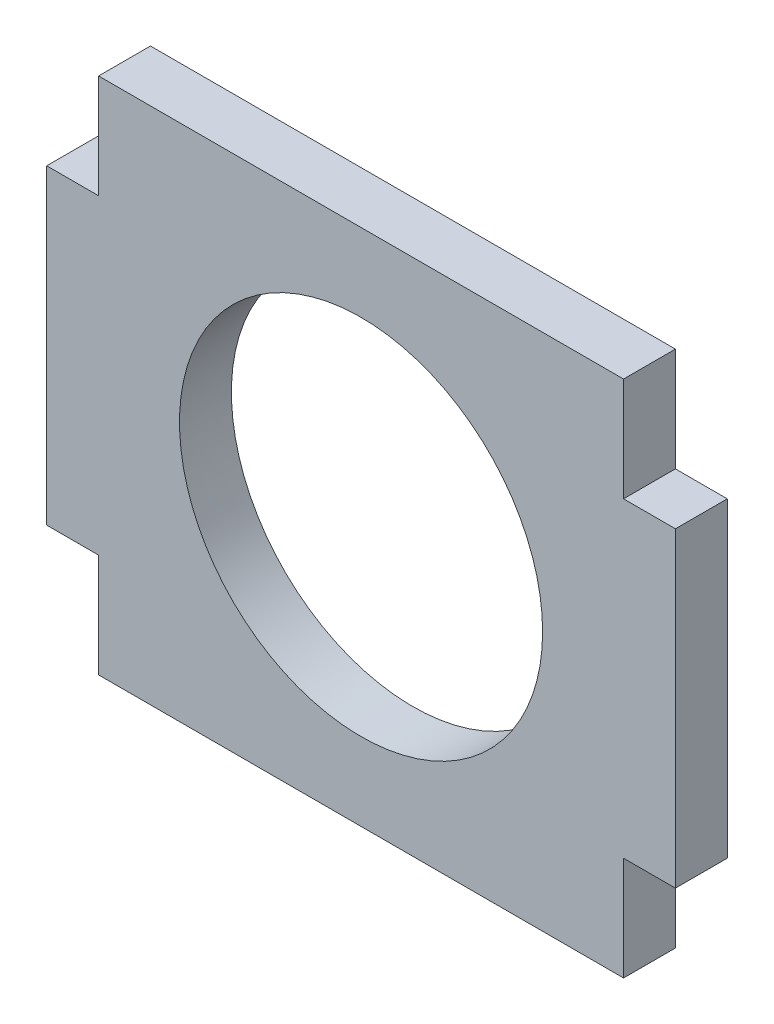
from build123d import *

# Parameters (mm, degrees)
SKETCH1_R           = 11.1125
BOSS_EXTRUDE1_DEPTH = 3.175


with BuildPart() as part:
    # Sketch1 → Boss-Extrude1 (new body)
    with BuildSketch(Plane.XY):
        Polygon((-19.2405, -9.525), (-19.2405, 9.525), (-16.0655, 9.525), (-16.0655, 15.875), (16.0655, 15.875), (16.0655, 9.525), (19.2405, 9.525), (19.2405, -9.525), (16.0655, -9.525), (16.0655, -15.875), (-16.0655, -15.875), (-16.0655, -9.525), align=None)
        Circle(SKETCH1_R, mode=Mode.SUBTRACT)
    extrude(amount=BOSS_EXTRUDE1_DEPTH)


solid = part.part
